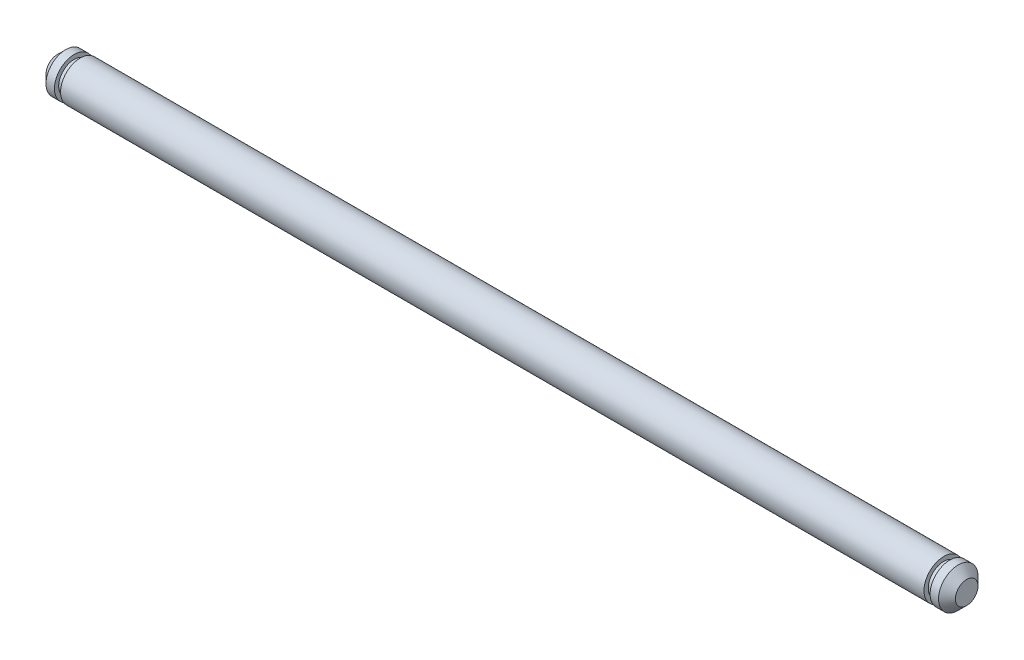
from build123d import *

# Parameters (mm, degrees)
CHAMFER1_SIZE = 1.016


with BuildPart() as part:
    # Sketch2 → Revolve1 (revolve)
    with BuildSketch(Plane.XY):
        Polygon((0, 2.38125), (104.14, 2.38125), (104.14, 1.8669), (104.8766, 1.8669), (104.8766, 2.38125), (106.9086, 2.38125), (106.9086, 0), (-2.7686, 0), (-2.7686, 2.38125), (-0.7366, 2.38125), (-0.7366, 1.8669), (0, 1.8669), align=None)
    revolve(axis=Axis((0, 0, 0), (-1, 0, 0)))

    # Chamfer1
    chamfer1_edges = [part.edges().sort_by_distance(p)[0] for p in [
        (-2.7686, -2.38125, 0),
        (106.9086, -2.38125, 0),
    ]]
    chamfer(chamfer1_edges, length=CHAMFER1_SIZE)


solid = part.part
